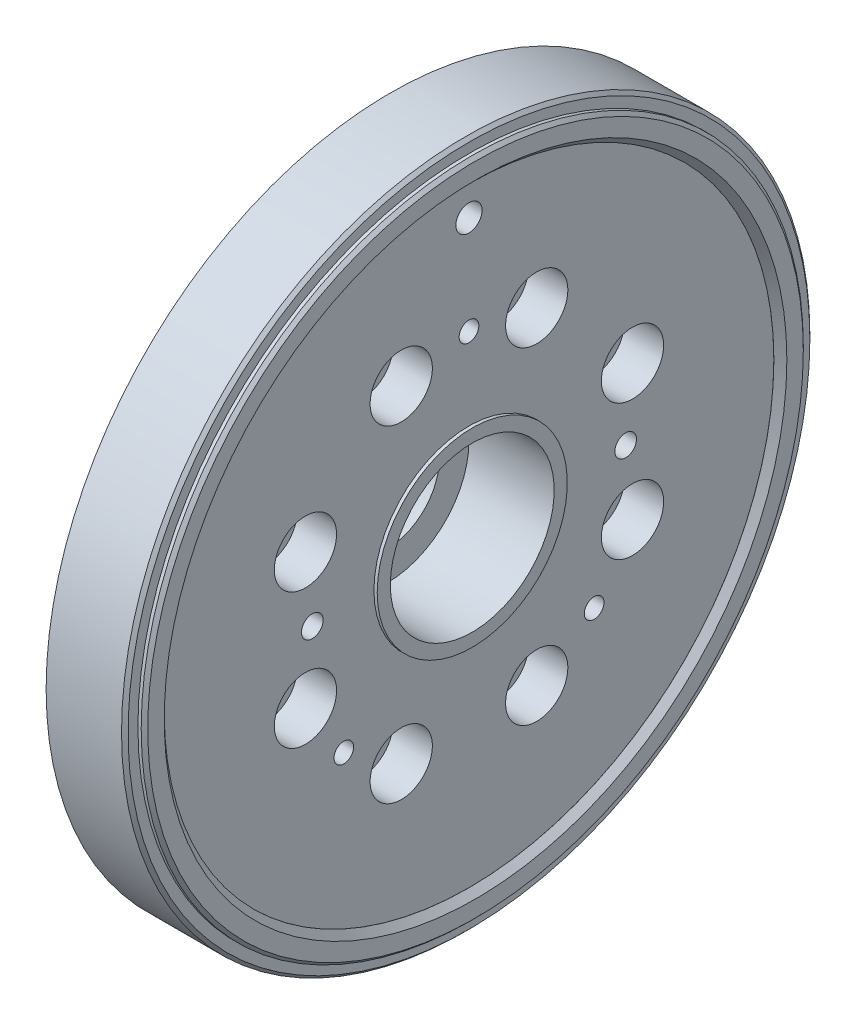
from build123d import *

# Parameters (mm, degrees)
SKIZZE22_R                            = 12.5
SCHNITT_LINEAR_AUSTRAGEN16_DEPTH      = 12.5
SCHNITT_LINEAR_AUSTRAGEN17_REACH      = 27
SKIZZE23_R                            = 1.5
SKIZZE24_R                            = 2.75
SCHNITT_LINEAR_AUSTRAGEN18_DEPTH      = 26
KREISMUSTER4_COUNT                    = 8
SKIZZE25_R                            = 4.75
SCHNITT_LINEAR_AUSTRAGEN19_DEPTH      = 6
KREISMUSTER5_COUNT                    = 8
SKIZZE26_R                            = 2
SCHNITT_LINEAR_AUSTRAGEN20_DEPTH      = 2
SCHNITT_LINEAR_AUSTRAGEN20_DEPTH_BACK = 6
SKIZZE27_R                            = 8
SCHNITT_LINEAR_AUSTRAGEN21_DEPTH      = 13.5
VERRUNDUNG8_R                         = 0.2
VERRUNDUNG9_R                         = 0.2
FASE6_SIZE                            = 0.99
M4_GEWINDEBOHRUNG1_D                  = 3.3
M4_GEWINDEBOHRUNG1_DEPTH              = 10
M4_GEWINDEBOHRUNG1_TIP                = 0.991420021
FASE7_SIZE                            = 0.5
FASE8_SIZE                            = 0.25


with BuildPart() as part:
    # Skizze1 → Rotation1 (revolve)
    with BuildSketch(Plane.XY, mode=Mode.PRIVATE) as rotation1_sk:
        Polygon((0, 0), (0, -10), (11, -10), (11, -15), (13, -15), (13, -31), (16, -31), (16, -37), (13, -37), (13, -41), (16, -41), (16, -49), (13, -52.5), (25, -52.5), (25, -50.5), (26, -50.5), (26, -46.5), (25, -46.5), (25, -14.5), (25.5, -14.5), (25.5, -12.5), (25, -12.5), (25, 0), align=None)
    revolve(rotation1_sk.sketch.rotate(Axis((-20.806451613, 0, 0), (1, 0, 0)), 270), axis=Axis((-20.806451613, 0, 0), (1, 0, 0)))  # turned: the seam where the file's is

    # Skizze22 → Schnitt-Linear austragen16 (cut)
    with BuildSketch(Plane(origin=(25, 0, 0), x_dir=(0, 0, -1), z_dir=(1, 0, 0))):
        with Locations(Location((0, 0, 0), (0, 0, 180))):  # turned: the seam where the file's is
            Circle(SKIZZE22_R)
    extrude(amount=-SCHNITT_LINEAR_AUSTRAGEN16_DEPTH, mode=Mode.SUBTRACT)

    # Skizze23 → Schnitt-Linear austragen17 (cut, up to next)
    with BuildSketch(Plane(origin=(25, 0, 0), x_dir=(0, 0, -1), z_dir=(1, 0, 0)), mode=Mode.PRIVATE) as schnitt_linear_austragen17_sk1:
        with Locations((0, 27)):
            Circle(SKIZZE23_R)
    schnitt_linear_austragen17_tool1 = extrude(schnitt_linear_austragen17_sk1.sketch, amount=-SCHNITT_LINEAR_AUSTRAGEN17_REACH, mode=Mode.PRIVATE) & part.part
    add(schnitt_linear_austragen17_tool1.solids().sort_by_distance((25, 27, 0))[0], mode=Mode.SUBTRACT)
    # Skizze23 → Schnitt-Linear austragen17 (cut, up to next)
    with BuildSketch(Plane(origin=(25, 0, 0), x_dir=(0, 0, -1), z_dir=(1, 0, 0)), mode=Mode.PRIVATE) as schnitt_linear_austragen17_sk2:
        with Locations((-19.091883092, -19.091883092)):
            Circle(SKIZZE23_R)
    schnitt_linear_austragen17_tool2 = extrude(schnitt_linear_austragen17_sk2.sketch, amount=-SCHNITT_LINEAR_AUSTRAGEN17_REACH, mode=Mode.PRIVATE) & part.part
    add(schnitt_linear_austragen17_tool2.solids().sort_by_distance((25, -19.091883, 19.091883))[0], mode=Mode.SUBTRACT)
    # Skizze23 → Schnitt-Linear austragen17 (cut, up to next)
    with BuildSketch(Plane(origin=(25, 0, 0), x_dir=(0, 0, -1), z_dir=(1, 0, 0)), mode=Mode.PRIVATE) as schnitt_linear_austragen17_sk3:
        with Locations((19.091883092, -19.091883092)):
            Circle(SKIZZE23_R)
    schnitt_linear_austragen17_tool3 = extrude(schnitt_linear_austragen17_sk3.sketch, amount=-SCHNITT_LINEAR_AUSTRAGEN17_REACH, mode=Mode.PRIVATE) & part.part
    add(schnitt_linear_austragen17_tool3.solids().sort_by_distance((25, -19.091883, -19.091883))[0], mode=Mode.SUBTRACT)

    # Skizze24 → Schnitt-Linear austragen18 (cut, through all)
    with BuildSketch(Plane(origin=(25, 0, 0), x_dir=(0, 0, -1), z_dir=(1, 0, 0))):
        with Locations((10.332452674, 24.944747378)):
            Circle(SKIZZE24_R)
    schnitt_linear_austragen18 = extrude(amount=-SCHNITT_LINEAR_AUSTRAGEN18_DEPTH, mode=Mode.SUBTRACT)

    # Kreismuster4: Schnitt-Linear austragen18 ×8 about axis
    kreismuster4_axis = Axis((0, 0, 0), (1, 0, 0))
    for i in range(1, KREISMUSTER4_COUNT):
        add(schnitt_linear_austragen18.rotate(kreismuster4_axis, i * 360 / KREISMUSTER4_COUNT), mode=Mode.SUBTRACT)

    # Skizze25 → Schnitt-Linear austragen19 (cut)
    with BuildSketch(Plane(origin=(25, 0, 0), x_dir=(0, 0, -1), z_dir=(1, 0, 0))):
        with Locations((10.332452674, 24.944747378)):
            Circle(SKIZZE25_R)
    schnitt_linear_austragen19 = extrude(amount=-SCHNITT_LINEAR_AUSTRAGEN19_DEPTH, mode=Mode.SUBTRACT)

    # Kreismuster5: Schnitt-Linear austragen19 ×8 about axis
    kreismuster5_axis = Axis((0, 0, 0), (1, 0, 0))
    for i in range(1, KREISMUSTER5_COUNT):
        add(schnitt_linear_austragen19.rotate(kreismuster5_axis, i * 360 / KREISMUSTER5_COUNT), mode=Mode.SUBTRACT)

    # Skizze26 → Schnitt-Linear austragen20 (cut, two sides)
    with BuildSketch(Plane(origin=(25, 0, 0), x_dir=(0, 0, -1), z_dir=(1, 0, 0))) as schnitt_linear_austragen20_sk:
        with Locations((0, 42)):
            Circle(SKIZZE26_R)
    extrude(amount=SCHNITT_LINEAR_AUSTRAGEN20_DEPTH, mode=Mode.SUBTRACT)
    extrude(schnitt_linear_austragen20_sk.sketch, amount=-SCHNITT_LINEAR_AUSTRAGEN20_DEPTH_BACK, mode=Mode.SUBTRACT)

    # Skizze27 → Schnitt-Linear austragen21 (cut, through all)
    with BuildSketch(Plane(origin=(12.5, 0, 0), x_dir=(0, 0, -1), z_dir=(1, 0, 0))):
        Circle(SKIZZE27_R)
    extrude(amount=-SCHNITT_LINEAR_AUSTRAGEN21_DEPTH, mode=Mode.SUBTRACT)

    # Verrundung8
    verrundung8_edges = [part.edges().sort_by_distance(p)[0] for p in [
        (13, 0, -31),
        (11, 0, -15),
        (0, 0, -10),
    ]]
    fillet(verrundung8_edges, radius=VERRUNDUNG8_R)

    # Verrundung9
    verrundung9_edges = [part.edges().sort_by_distance(p)[0] for p in [
        (13, 0, -41),
        (13, 0, -37),
    ]]
    fillet(verrundung9_edges, radius=VERRUNDUNG9_R)

    # Fase6
    fase6_edges = [part.edges().sort_by_distance(p)[0] for p in [
        (26, 0, -46.5),
    ]]
    chamfer(fase6_edges, length=FASE6_SIZE)

    # M4 Gewindebohrung1
    with Locations(Plane(origin=(25, 0, 0), x_dir=(0, 0, -1), z_dir=(1, 0, 0))):
        with Locations((-23.9, 0), (23.9, 0)):
            Hole(M4_GEWINDEBOHRUNG1_D / 2, depth=M4_GEWINDEBOHRUNG1_DEPTH)
            with Locations((0, 0, -(M4_GEWINDEBOHRUNG1_DEPTH + M4_GEWINDEBOHRUNG1_TIP / 2))):  # 118° drill point
                Cone(0, M4_GEWINDEBOHRUNG1_D / 2, M4_GEWINDEBOHRUNG1_TIP, mode=Mode.SUBTRACT)

    # Fase7
    fase7_edges = [part.edges().sort_by_distance(p)[0] for p in [
        (26, 0, -50.5),
        (25, 0, -52.5),
    ]]
    chamfer(fase7_edges, length=FASE7_SIZE)

    # Fase8
    fase8_edges = [part.edges().sort_by_distance(p)[0] for p in [
        (0, 0, 8),
    ]]
    chamfer(fase8_edges, length=FASE8_SIZE)


solid = part.part
